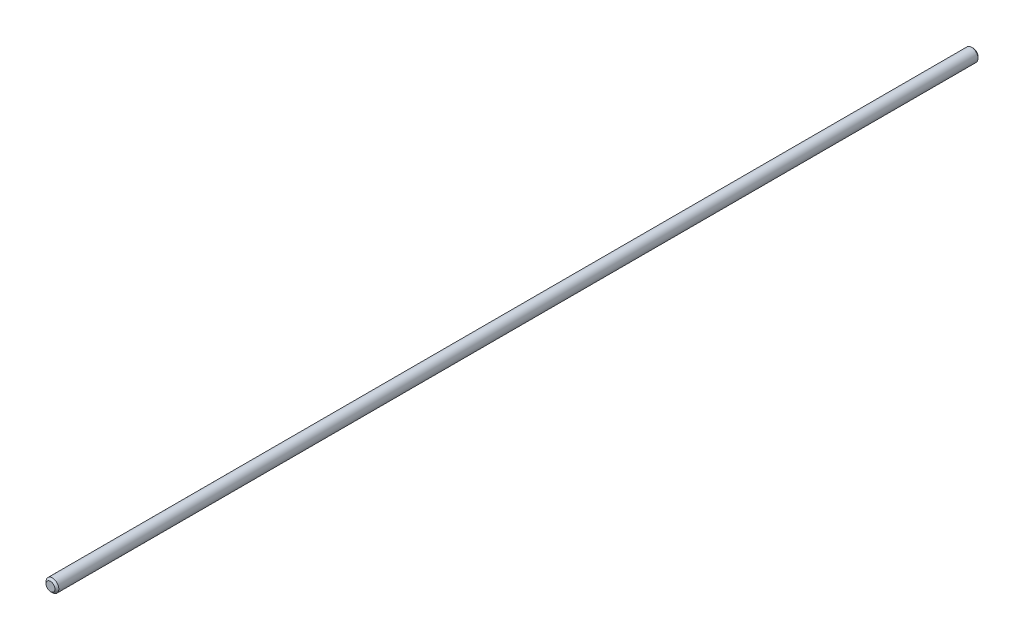
from build123d import *

# Parameters (mm, degrees)
SKETCH2_W     = 457.2
SKETCH2_H     = 3.175
CHAMFER1_SIZE = 0.9525


with BuildPart() as part:
    # Sketch2 → Revolve1 (revolve)
    with BuildSketch(Plane(origin=(0, 0, 0), x_dir=(0, 0, -1), z_dir=(1, 0, 0))):
        with Locations((0, 1.5875)):
            Rectangle(SKETCH2_W, SKETCH2_H)
    revolve(axis=Axis((0, 0, 228.6), (0, 0, -1)))

    # Chamfer1
    chamfer1_edges = [part.edges().sort_by_distance(p)[0] for p in [
        (0, -3.175, -228.6),
        (0, -3.175, 228.6),
    ]]
    chamfer(chamfer1_edges, length=CHAMFER1_SIZE)


solid = part.part
